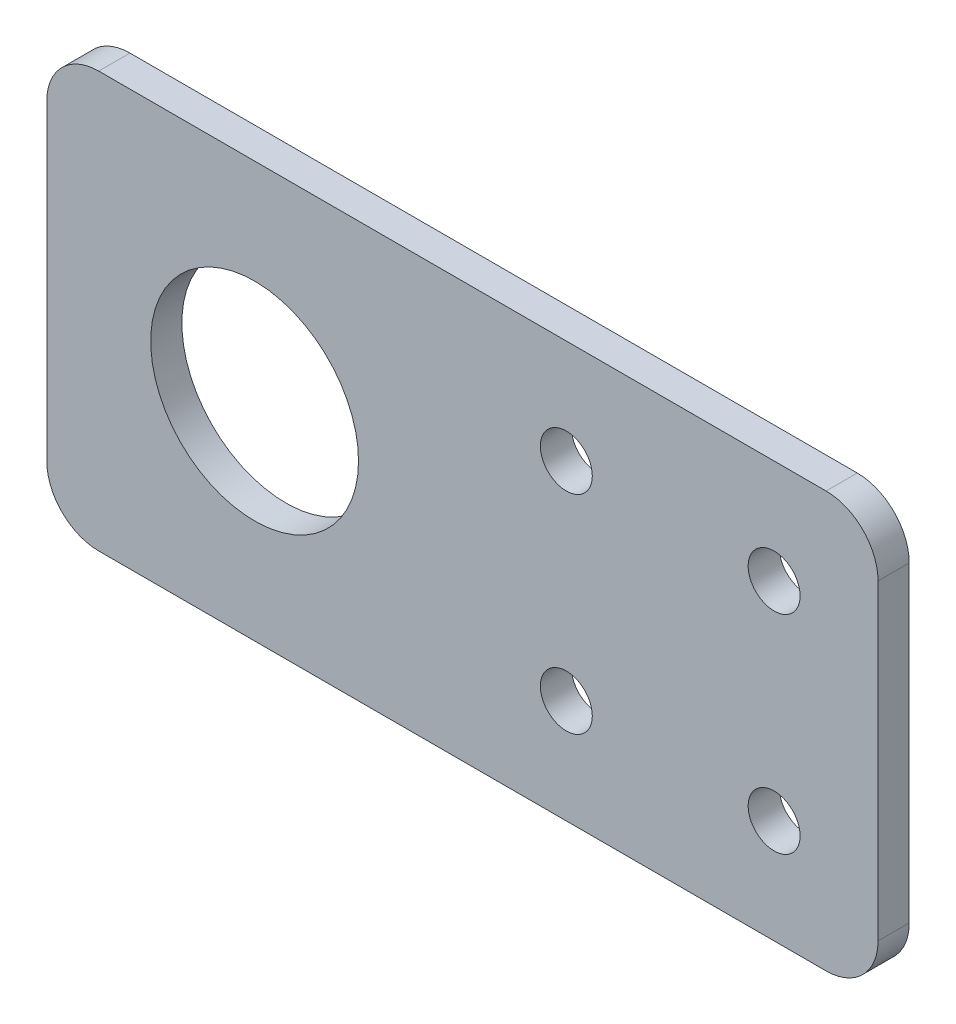
from build123d import *

# Parameters (mm, degrees)
SKETCH1_W           = 80
SKETCH1_H           = 40
SKETCH1_R           = 10
SKETCH1_R_2         = 2.5
BOSS_EXTRUDE1_DEPTH = 3
FILLET1_R           = 5


with BuildPart() as part:
    # Sketch1 → Boss-Extrude1 (new body)
    with BuildSketch(Plane.XY):
        with Locations((-40, 0)):
            Rectangle(SKETCH1_W, SKETCH1_H)
        with Locations((-60, 0)):
            Circle(SKETCH1_R, mode=Mode.SUBTRACT)
        with Locations((-10, 10)):
            Circle(SKETCH1_R_2, mode=Mode.SUBTRACT)
        with Locations((-10, -10)):
            Circle(SKETCH1_R_2, mode=Mode.SUBTRACT)
        with Locations((-30, -10)):
            Circle(SKETCH1_R_2, mode=Mode.SUBTRACT)
        with Locations((-30, 10)):
            Circle(SKETCH1_R_2, mode=Mode.SUBTRACT)
    extrude(amount=BOSS_EXTRUDE1_DEPTH)

    # Fillet1
    fillet1_edges = [part.edges().sort_by_distance(p)[0] for p in [
        (-80, 20, 1.5),
        (0, 20, 1.5),
        (0, -20, 1.5),
        (-80, -20, 1.5),
    ]]
    fillet(fillet1_edges, radius=FILLET1_R)


solid = part.part
